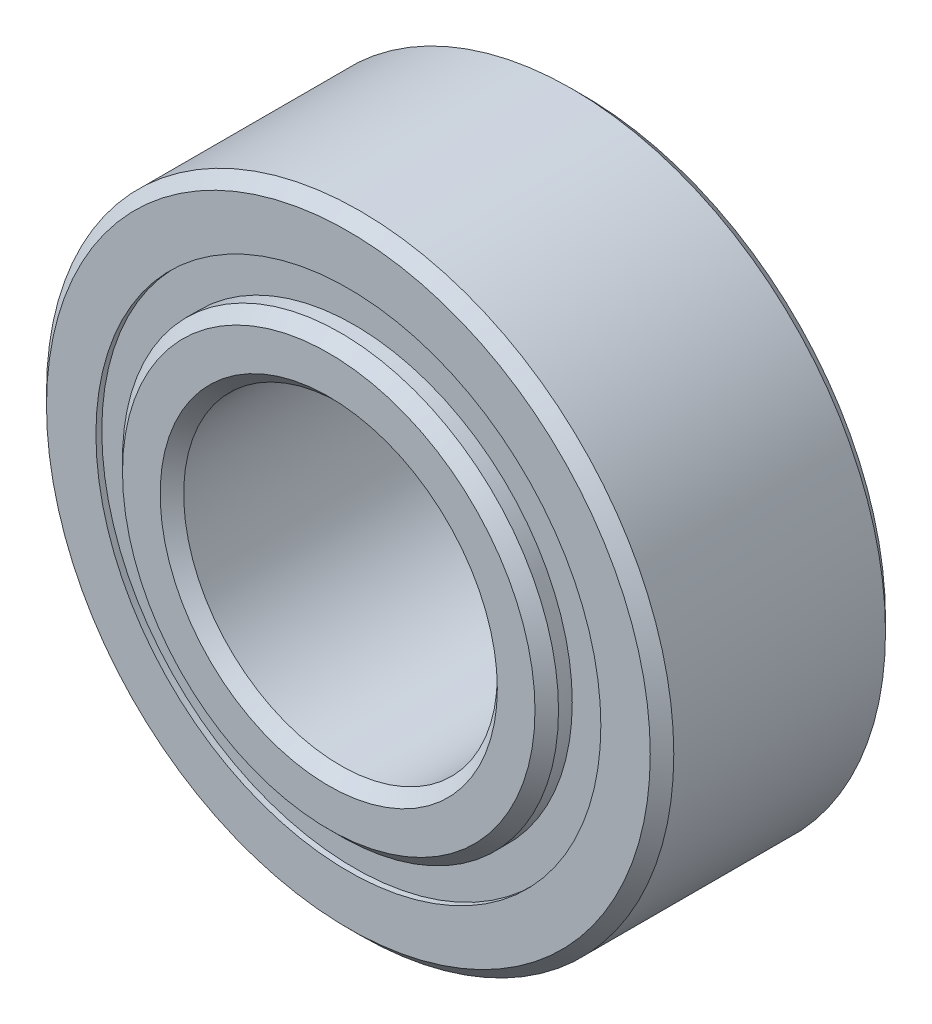
from build123d import *

# Parameters (mm, degrees)
CIRPATTERN1_COUNT = 10
SKETCH5_W         = 1.147826059
SKETCH5_H         = 0.697802198


with BuildPart() as part:
    # Sketch1 → Revolve1 (revolve)
    with BuildSketch(Plane(origin=(0, 0, 0), x_dir=(0, 0, -1), z_dir=(1, 0, 0))):
        with BuildLine():
            Line((2.143125, 6.35), (-2.143125, 6.35))
            Line((-2.143125, 6.35), (-2.38125, 6.111875))
            Line((-2.38125, 6.111875), (-2.38125, 5.111401099))
            Line((-2.38125, 5.111401099), (-1.058333333, 5.111401099))
            ThreePointArc((-1.058333333, 5.111401099), (0, 5.876861441), (1.058333333, 5.111401099))
            Line((1.058333333, 5.111401099), (2.38125, 5.111401099))
            Line((2.38125, 5.111401099), (2.38125, 6.111875))
            Line((2.38125, 6.111875), (2.143125, 6.35))
        make_face()
    revolve(axis=Axis((0, 0, 2.38125), (0, 0, -1)))


with BuildPart() as body_2:
    # Sketch3 → Revolve3 (revolve)
    with BuildSketch(Plane(origin=(0, 0, 0), x_dir=(0, 0, -1), z_dir=(1, 0, 0))):
        with BuildLine():
            Line((-2.77876, 3.413125), (-2.77876, 4.175473901))
            Line((-2.77876, 4.175473901), (-2.540635, 4.413598901))
            Line((-2.540635, 4.413598901), (-1.058333333, 4.413598901))
            ThreePointArc((-1.058333333, 4.413598901), (0, 3.648138559), (1.058333333, 4.413598901))
            Line((1.058333333, 4.413598901), (2.540635, 4.413598901))
            Line((2.540635, 4.413598901), (2.77876, 4.175473901))
            Line((2.77876, 4.175473901), (2.77876, 3.413125))
            Line((2.77876, 3.413125), (2.540635, 3.175))
            Line((2.540635, 3.175), (-2.540635, 3.175))
            Line((-2.540635, 3.175), (-2.77876, 3.413125))
        make_face()
    revolve(axis=Axis((0, 0, 2.38125), (0, 0, -1)))


with BuildPart() as body_3:
    # Sketch4 → Revolve4 (revolve)
    with BuildSketch(Plane(origin=(0, 0, 0), x_dir=(0, 0, -1), z_dir=(1, 0, 0))):
        with BuildLine():
            Line((-1.114361441, 4.7625), (1.114361441, 4.7625))
            ThreePointArc((1.114361441, 4.7625), (0, 5.876861441), (-1.114361441, 4.7625))
        make_face()
    revolve(axis=Axis((0, 4.7625, 1.114361441), (0, 0, -1)))


with BuildPart() as cirpattern1_1:
    # CirPattern1: pattern copy
    add(body_3.part.rotate(Axis((0, 0, -2.38125), (0, 0, 1)), 1 * 360 / CIRPATTERN1_COUNT))


with BuildPart() as cirpattern1_2:
    # CirPattern1: pattern copy
    add(body_3.part.rotate(Axis((0, 0, -2.38125), (0, 0, 1)), 2 * 360 / CIRPATTERN1_COUNT))


with BuildPart() as cirpattern1_3:
    # CirPattern1: pattern copy
    add(body_3.part.rotate(Axis((0, 0, -2.38125), (0, 0, 1)), 3 * 360 / CIRPATTERN1_COUNT))


with BuildPart() as cirpattern1_4:
    # CirPattern1: pattern copy
    add(body_3.part.rotate(Axis((0, 0, -2.38125), (0, 0, 1)), 4 * 360 / CIRPATTERN1_COUNT))


with BuildPart() as cirpattern1_5:
    # CirPattern1: pattern copy
    add(body_3.part.rotate(Axis((0, 0, -2.38125), (0, 0, 1)), 5 * 360 / CIRPATTERN1_COUNT))


with BuildPart() as cirpattern1_6:
    # CirPattern1: pattern copy
    add(body_3.part.rotate(Axis((0, 0, -2.38125), (0, 0, 1)), 6 * 360 / CIRPATTERN1_COUNT))


with BuildPart() as cirpattern1_7:
    # CirPattern1: pattern copy
    add(body_3.part.rotate(Axis((0, 0, -2.38125), (0, 0, 1)), 7 * 360 / CIRPATTERN1_COUNT))


with BuildPart() as cirpattern1_8:
    # CirPattern1: pattern copy
    add(body_3.part.rotate(Axis((0, 0, -2.38125), (0, 0, 1)), 8 * 360 / CIRPATTERN1_COUNT))


with BuildPart() as cirpattern1_9:
    # CirPattern1: pattern copy
    add(body_3.part.rotate(Axis((0, 0, -2.38125), (0, 0, 1)), 9 * 360 / CIRPATTERN1_COUNT))


with BuildPart() as body_13:
    # Sketch5 → Revolve5 (revolve)
    with BuildSketch(Plane(origin=(0, 0, 0), x_dir=(0, 0, -1), z_dir=(1, 0, 0))):
        with Locations((-1.688274471, 4.7625)):
            Rectangle(SKETCH5_W, SKETCH5_H)
        with Locations((1.688274471, 4.7625)):
            Rectangle(SKETCH5_W, SKETCH5_H)
    revolve(axis=Axis((0, 0, 2.38125), (0, 0, -1)))


solid = Compound([part.part, body_2.part, body_3.part, cirpattern1_1.part, cirpattern1_2.part, cirpattern1_3.part, cirpattern1_4.part, cirpattern1_5.part, cirpattern1_6.part, cirpattern1_7.part, cirpattern1_8.part, cirpattern1_9.part, body_13.part])
